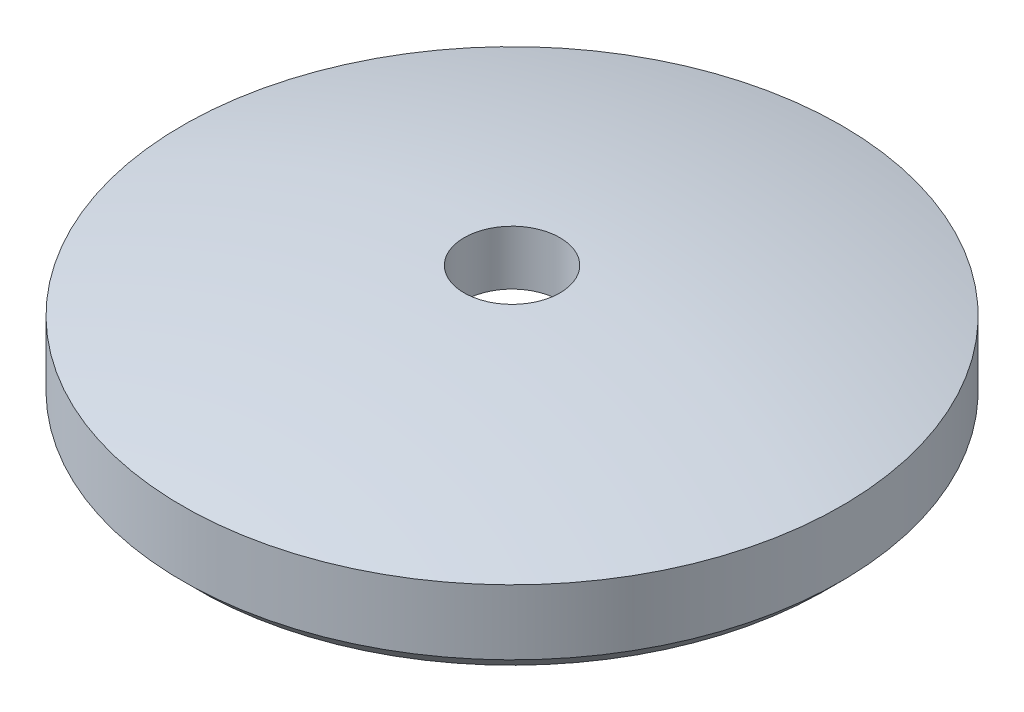
from build123d import *


with BuildPart() as part:
    # Sketch1 → Revolve1 (revolve)
    with BuildSketch(Plane.XY):
        with BuildLine():
            Line((0.074742787, 0.53), (0.074742787, 0.444967446))
            ThreePointArc((0.074742787, 0.444967446), (0.216566315, 0.407528436), (0.344313925, 0.335444176))
            Line((0.344313925, 0.335444176), (0.489237218, 0.335444176))
            Line((0.489237218, 0.335444176), (0.514237218, 0.360444176))
            Line((0.514237218, 0.360444176), (0.514237218, 0.46181705))
            ThreePointArc((0.514237218, 0.46181705), (0.296456726, 0.508585652), (0.074742787, 0.53))
        make_face()
    revolve(axis=Axis((0, 0.53, 0), (0, -1, 0)))


solid = part.part
